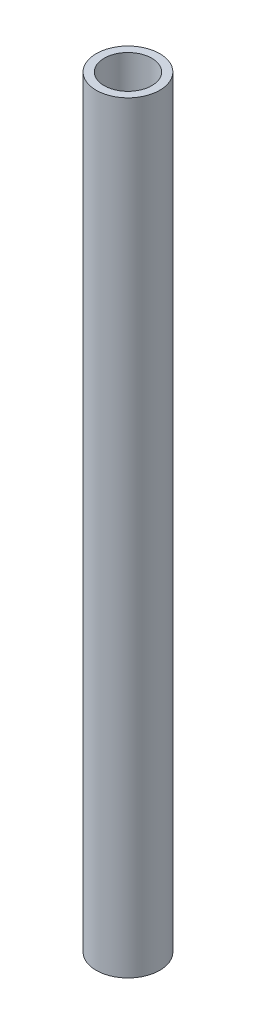
from build123d import *

# Parameters (mm, degrees)
SKETCH1_R           = 5
SKETCH1_R_2         = 3.75
BOSS_EXTRUDE1_DEPTH = 120


with BuildPart() as part:
    # Sketch1 → Boss-Extrude1 (new body)
    with BuildSketch(Plane(origin=(0, 0, 0), x_dir=(1, 0, 0), z_dir=(0, 1, 0))):
        Circle(SKETCH1_R)
        Circle(SKETCH1_R_2, mode=Mode.SUBTRACT)
    extrude(amount=BOSS_EXTRUDE1_DEPTH)


solid = part.part
